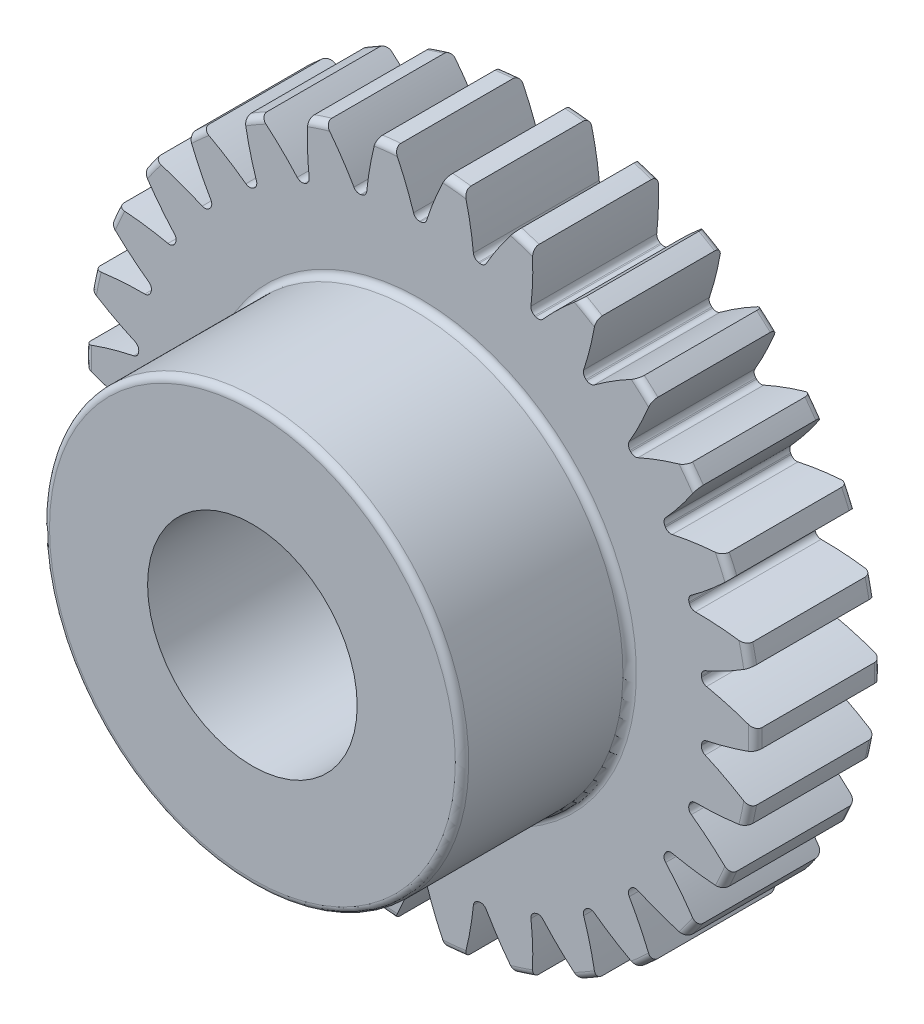
from build123d import *

# Parameters (mm, degrees)
FILLET2_R          = 0.16
CUT_EXTRUDE2_DEPTH = 4
CIRPATTERN1_COUNT  = 30


with BuildPart() as part:
    # Sketch4 → Revolve1 (revolve)
    with BuildSketch(Plane(origin=(0, 0, 0), x_dir=(0, 0, -1), z_dir=(1, 0, 0))):
        Polygon((-7, 2.5), (-7, 5), (-3, 5), (-3, 8), (0, 8), (0, 2.5), align=None)
    revolve(axis=Axis((0, 0, 3), (0, 0, 1)))

    # Fillet2
    fillet2_edges = [part.edges().sort_by_distance(p)[0] for p in [
        (0, -8, 0),
        (0, -8, 3),
        (0, -5, 3),
        (0, -5, 7),
    ]]
    fillet(fillet2_edges, radius=FILLET2_R)

    # Sketch7 → Cut-Extrude2 (cut, through all)
    with BuildSketch(Plane.XY.offset(3)):
        with BuildLine():
            ThreePointArc((-0.012921148, 6.749987633), (0, 6.75), (0.012921148, 6.749987633))
            ThreePointArc((0.012921148, 6.749987633), (0.101459928, 6.778693178), (0.156024335, 6.854097751))
            ThreePointArc((0.156024335, 6.854097751), (0.365165636, 7.424425108), (0.619776866, 7.975956158))
            ThreePointArc((0.619776866, 7.975956158), (0, 8), (-0.619776866, 7.975956158))
            ThreePointArc((-0.619776866, 7.975956158), (-0.365165636, 7.424425108), (-0.156024335, 6.854097751))
            ThreePointArc((-0.156024335, 6.854097751), (-0.101459928, 6.778693178), (-0.012921148, 6.749987633))
        make_face()
    cut_extrude2 = extrude(amount=-CUT_EXTRUDE2_DEPTH, mode=Mode.SUBTRACT)

    # CirPattern1: Cut-Extrude2 ×30 about axis
    cirpattern1_axis = Axis((0, 0, 0), (0, 0, 1))
    for i in range(1, CIRPATTERN1_COUNT):
        add(cut_extrude2.rotate(cirpattern1_axis, i * 360 / CIRPATTERN1_COUNT), mode=Mode.SUBTRACT)


solid = part.part
